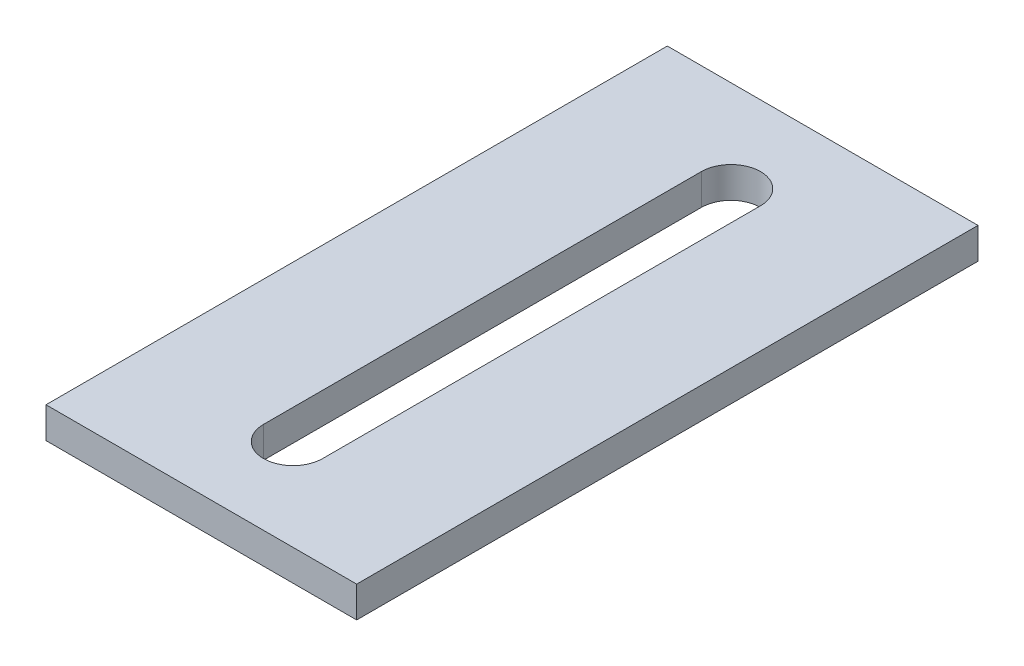
from build123d import *

# Parameters (mm, degrees)
BOSS_EXTRUDE1_DEPTH      = 2.5
BOSS_EXTRUDE1_DEPTH_BACK = 2.5
SKETCH1_W                = 50
SKETCH1_H                = 100


with BuildPart() as part:
    # Sketch1 → Boss-Extrude1 (new, two sides: drawn at the far end of the back side and taken through both)
    with BuildSketch(Plane(origin=(0, 0, 0), x_dir=(1, 0, 0), z_dir=(0, 1, 0)).offset(-BOSS_EXTRUDE1_DEPTH_BACK)):
        Rectangle(SKETCH1_W, SKETCH1_H)
        with BuildLine():
            Line((4.7625, 35.2375), (4.7625, -35.2375))
            ThreePointArc((4.7625, -35.2375), (0, -40), (-4.7625, -35.2375))
            Line((-4.7625, -35.2375), (-4.7625, 35.2375))
            ThreePointArc((-4.7625, 35.2375), (0, 40), (4.7625, 35.2375))
        make_face(mode=Mode.SUBTRACT)
    extrude(amount=BOSS_EXTRUDE1_DEPTH + BOSS_EXTRUDE1_DEPTH_BACK)


solid = part.part
